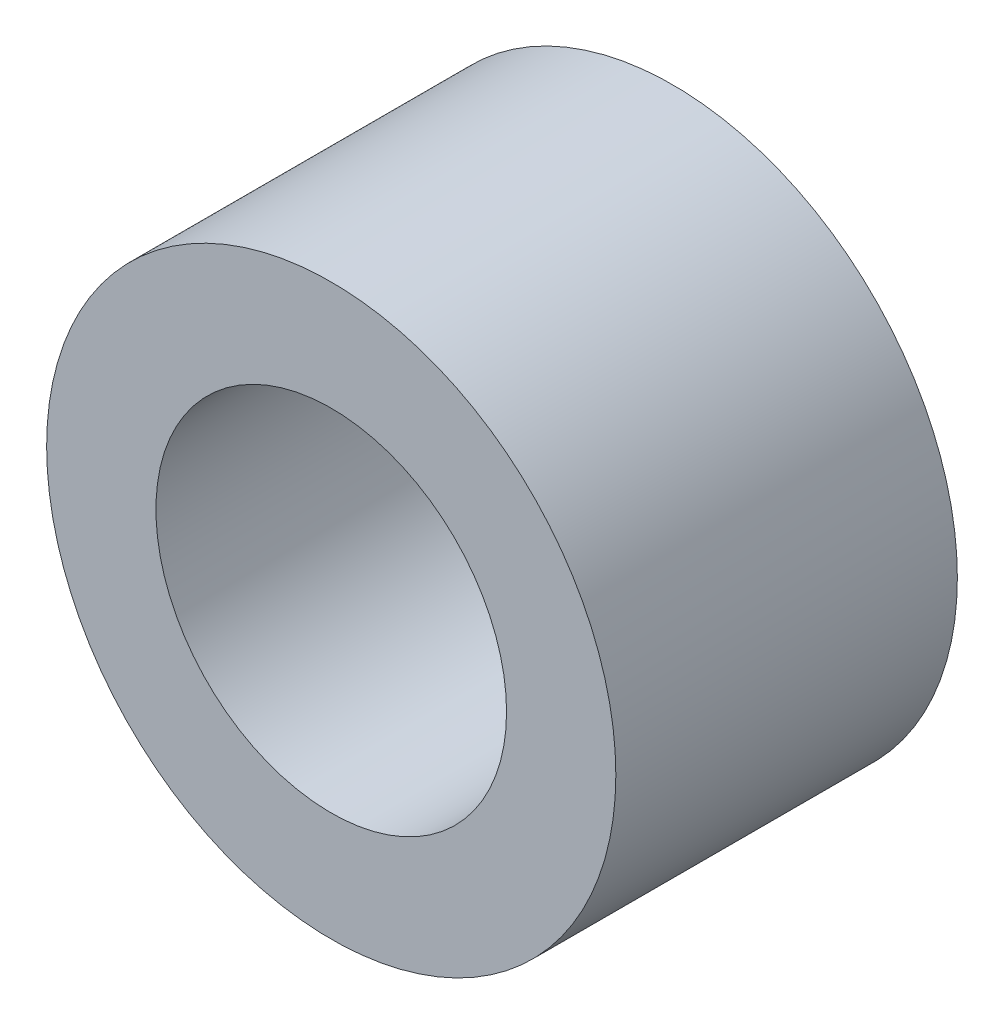
from build123d import *

# Parameters (mm, degrees)
SKETCH1_R           = 7.9375
SKETCH1_R_2         = 4.8895
BOSS_EXTRUDE1_DEPTH = 9.525


with BuildPart() as part:
    # Sketch1 → Boss-Extrude1 (new body)
    with BuildSketch(Plane.XY):
        Circle(SKETCH1_R)
        Circle(SKETCH1_R_2, mode=Mode.SUBTRACT)
    extrude(amount=BOSS_EXTRUDE1_DEPTH)


solid = part.part
